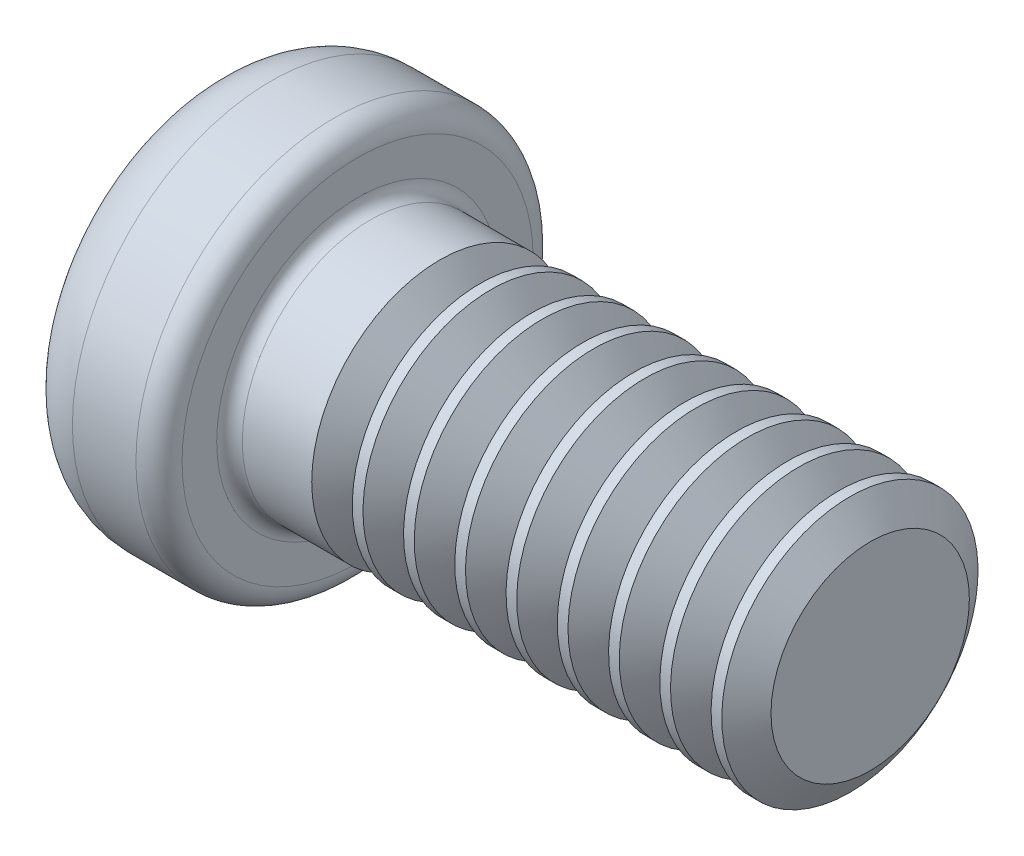
from build123d import *

# Parameters (mm, degrees)
FILLET1_R       = 0.1
SKETCH3_W       = 0.48
SKETCH3_H       = 2.1
SKETCH4_W       = 0.48
SKETCH4_H       = 0.68402847
RECPAT_COUNT    = 2
RECPAT_ANGLE    = 90
THDSCHPAT_COUNT = 9
THDSCHPAT_PITCH = 0.4


with BuildPart() as part:
    # BodySke → Base-Revolve (revolve)
    with BuildSketch(Plane.XY):
        with BuildLine():
            Line((1.3, 1), (1.3, 1.37))
            ThreePointArc((1.3, 1.37), (1.247279221, 1.497279221), (1.12, 1.55))
            Line((1.12, 1.55), (0.624214356, 1.55))
            ThreePointArc((0.624214356, 1.55), (0.314644763, 1.442640633), (0.138015951, 1.166666667))
            ThreePointArc((0.138015951, 1.166666667), (0.034623869, 0.587400952), (0, 0))
            Line((0, 0), (5.3, 0))
            Line((5.3, 0), (5.3, 1))
            Line((5.3, 1), (1.3, 1))
        make_face()
    revolve(axis=Axis((-25.4, 0, 0), (1, 0, 0)))

    # Fillet1
    fillet1_edges = [part.edges().sort_by_distance(p)[0] for p in [
        (1.3, -1, 0),
    ]]
    fillet(fillet1_edges, radius=FILLET1_R)

    # Sketch3 → Recess section 0
    with BuildSketch(Plane(origin=(0, 0, 0), x_dir=(0, 0, -1), z_dir=(1, 0, 0))):
        Rectangle(SKETCH3_W, SKETCH3_H)
    # Sketch4 → Recess section 1
    with BuildSketch(Plane(origin=(1.42, 0, 0), x_dir=(0, 0, -1), z_dir=(1, 0, 0))):
        Rectangle(SKETCH4_W, SKETCH4_H)
    recess = loft(mode=Mode.SUBTRACT)

    # RecPat: Recess ×2 about axis
    recpat_axis = Axis((0, 0, 0), (1, 0, 0))
    for i in range(1, RECPAT_COUNT):
        add(recess.rotate(recpat_axis, i * RECPAT_ANGLE / (RECPAT_COUNT - 1)), mode=Mode.SUBTRACT)

    # RecCorSke → RecessCore (revolve, cut)
    with BuildSketch(Plane.XY):
        Polygon((0, 0), (0, 0.454796073), (1.42, 0.3555), (1.535508952, 0), align=None)
    revolve(axis=Axis((-3.175, 0, 0), (1, 0, 0)), mode=Mode.SUBTRACT)

    # ThdSchSke → ThreadSchematic (revolve, cut)
    with BuildSketch(Plane.XY):
        Polygon((2.1, -0.774), (1.941753096, -1), (1.941753096, -1.25), (2.258246904, -1.25), (2.258246904, -1), align=None)
    threadschematic = revolve(axis=Axis((-3.175, 0, 0), (1, 0, 0)), mode=Mode.SUBTRACT)

    # ThdSchPat: ThreadSchematic ×9
    with Locations(*[(i * THDSCHPAT_PITCH, 0, 0) for i in range(1, THDSCHPAT_COUNT)]):
        add(threadschematic, mode=Mode.SUBTRACT)


solid = part.part
